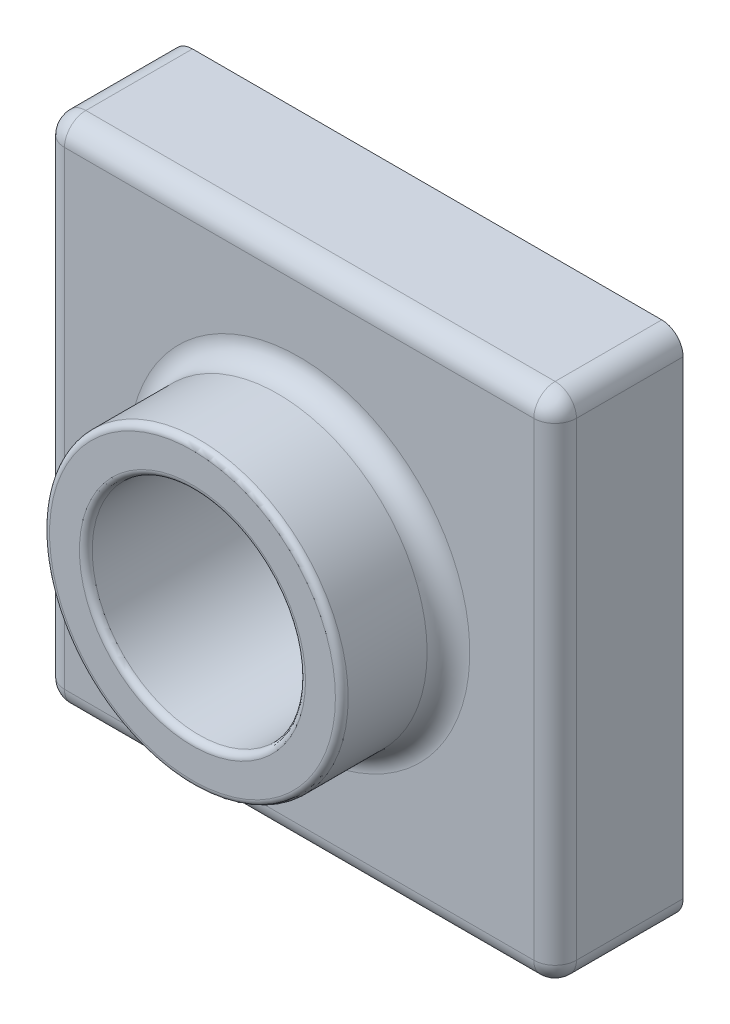
from build123d import *

# Parameters (mm, degrees)
SKETCH3_W           = 120
SKETCH3_H           = 120
BOSS_EXTRUDE1_DEPTH = 30
SKETCH4_R           = 35
BOSS_EXTRUDE2_DEPTH = 25
SKETCH6_R           = 25
CUT_EXTRUDE1_DEPTH  = 56
FILLET3_R           = 1.5
FILLET4_R           = 5
FILLET8_R           = 5
SHELL1_T            = -2


with BuildPart() as part:
    # Sketch3 → Boss-Extrude1 (new body)
    with BuildSketch(Plane.XY):
        with Locations((60, 60)):
            Rectangle(SKETCH3_W, SKETCH3_H)
    extrude(amount=BOSS_EXTRUDE1_DEPTH)

    # Sketch4 → Boss-Extrude2 (add)
    with BuildSketch(Plane.XY.offset(30)):
        with Locations((60, 60)):
            Circle(SKETCH4_R)
    extrude(amount=BOSS_EXTRUDE2_DEPTH)

    # Sketch6 → Cut-Extrude1 (cut, through all)
    with BuildSketch(Plane.XY.offset(55)):
        with Locations((60, 60)):
            Circle(SKETCH6_R)
    extrude(amount=-CUT_EXTRUDE1_DEPTH, mode=Mode.SUBTRACT)

    # Fillet3
    fillet3_edges = [part.edges().sort_by_distance(p)[0] for p in [
        (25, 60, 55),
        (35, 60, 55),
    ]]
    fillet(fillet3_edges, radius=FILLET3_R)

    # Fillet4
    fillet4_edges = [part.edges().sort_by_distance(p)[0] for p in [
        (0, 120, 15),
        (120, 120, 15),
        (120, 0, 15),
        (0, 0, 15),
    ]]
    fillet(fillet4_edges, radius=FILLET4_R)

    # Fillet8
    fillet8_edges = [part.edges().sort_by_distance(p)[0] for p in [
        (25, 60, 30),
        (60, 0, 30),
        (0, 60, 30),
        (120, 60, 30),
        (60, 120, 30),
        (118.535533906, 118.535533906, 30),
        (1.464466094, 118.535533906, 30),
        (118.535533906, 1.464466094, 30),
        (1.464466094, 1.464466094, 30),
    ]]
    fillet(fillet8_edges, radius=FILLET8_R)

    # Shell1
    shell1_openings = [part.faces().sort_by_distance(p)[0] for p in [
        (85, 60, 0),
    ]]
    offset(amount=SHELL1_T, openings=shell1_openings, kind=Kind.INTERSECTION)


solid = part.part
